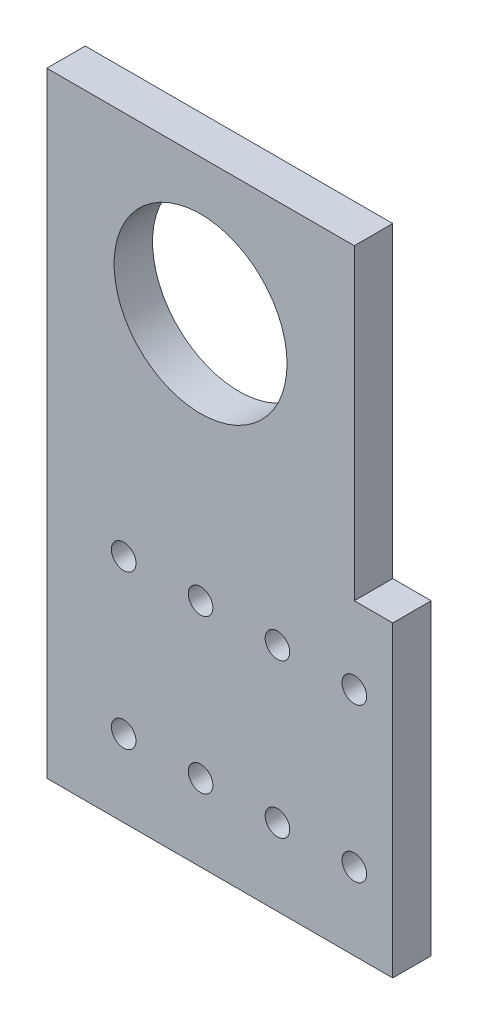
from build123d import *

# Parameters (mm, degrees)
BOSS_EXTRUDE1_DEPTH = 6.35
SKETCH3_R           = 14.2875
SKETCH3_R_2         = 2.032
CUT_EXTRUDE1_DEPTH  = 6.35


with BuildPart() as part:
    # Sketch2 → Boss-Extrude1 (new body)
    with BuildSketch(Plane.XY):
        Polygon((-125.79203122, -159.641560721), (-74.99203122, -159.641560721), (-68.64203122, -159.641560721), (-68.64203122, -108.841560721), (-74.99203122, -108.841560721), (-74.99203122, -58.041560721), (-125.79203122, -58.041560721), align=None)
    extrude(amount=BOSS_EXTRUDE1_DEPTH)

    # Sketch3 → Cut-Extrude1 (cut)
    with BuildSketch(Plane.XY.offset(6.35)):
        with Locations((-100.39203122, -80.483788015)):
            Circle(SKETCH3_R)
        with Locations((-87.69203122, -146.941560721)):
            Circle(SKETCH3_R_2)
        with Locations((-113.09203122, -146.941560721)):
            Circle(SKETCH3_R_2)
        with Locations((-100.39203122, -146.941560721)):
            Circle(SKETCH3_R_2)
        with Locations((-74.99203122, -146.941560721)):
            Circle(SKETCH3_R_2)
        with Locations((-113.09203122, -121.541560721)):
            Circle(SKETCH3_R_2)
        with Locations((-87.69203122, -121.541560721)):
            Circle(SKETCH3_R_2)
        with Locations((-74.99203122, -121.541560721)):
            Circle(SKETCH3_R_2)
        with Locations((-100.39203122, -121.541560721)):
            Circle(SKETCH3_R_2)
    extrude(amount=-CUT_EXTRUDE1_DEPTH, mode=Mode.SUBTRACT)


solid = part.part
